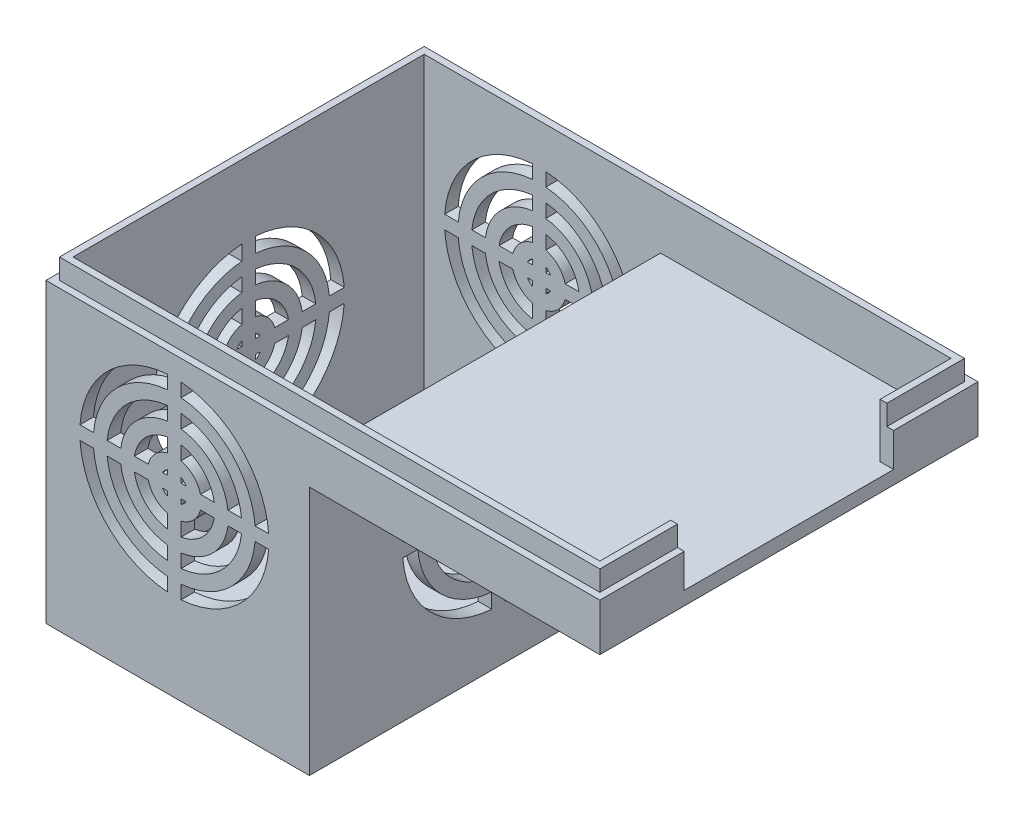
from build123d import *

# Parameters (mm, degrees)
SKETCH1_W               = 82
SKETCH1_H               = 56
BOSS_EXTRUDE1_DEPTH     = 47
SKETCH2_W               = 82
SKETCH2_H               = 56
SKETCH2_W_2             = 80
SKETCH2_H_2             = 54
CUT_EXTRUDE1_DEPTH      = 3
SKETCH3_W               = 43
SKETCH3_H               = 37
CUT_EXTRUDE2_DEPTH      = 72
CUT_EXTRUDE3_DEPTH      = 8
SKETCH4_W               = 35
SKETCH4_H               = 52
CUT_EXTRUDE4_DEPTH      = 37
SKETCH5_W               = 31
SKETCH5_H               = 16
CUT_EXTRUDE5_DEPTH      = 10
CUT_EXTRUDE5_DEPTH_BACK = 11
CUT_EXTRUDE6_DEPTH      = 108
CUT_EXTRUDE7_DEPTH      = 63


with BuildPart() as part:
    # Sketch1 → Boss-Extrude1 (new body)
    with BuildSketch(Plane(origin=(0, 0, 0), x_dir=(1, 0, 0), z_dir=(0, 1, 0))):
        Rectangle(SKETCH1_W, SKETCH1_H)
    extrude(amount=BOSS_EXTRUDE1_DEPTH)

    # Sketch2 → Cut-Extrude1 (cut)
    with BuildSketch(Plane(origin=(0, 47, 0), x_dir=(1, 0, 0), z_dir=(0, 1, 0))):
        Rectangle(SKETCH2_W, SKETCH2_H)
        Rectangle(SKETCH2_W_2, SKETCH2_H_2, mode=Mode.SUBTRACT)
    extrude(amount=-CUT_EXTRUDE1_DEPTH, mode=Mode.SUBTRACT)

    # Sketch3 → Cut-Extrude2 (cut)
    with BuildSketch(Plane.XY.offset(28)):
        with Locations((19.5, 18.5)):
            Rectangle(SKETCH3_W, SKETCH3_H)
    extrude(amount=-CUT_EXTRUDE2_DEPTH, mode=Mode.SUBTRACT)

    # 3DSketch2 → Cut-Extrude3 (cut)
    with BuildSketch(Plane(origin=(39, 47, -26), x_dir=(-0.8320502943378437, 0, 0.5547001962252293), z_dir=(0, -1, 0))):
        Polygon((0, 0), (64.899922958, 43.266615306), (93.744333162, 0), (28.844410204, -43.266615306), align=None)
    extrude(amount=CUT_EXTRUDE3_DEPTH, mode=Mode.SUBTRACT)

    # Sketch4 → Cut-Extrude4 (cut)
    with BuildSketch(Plane(origin=(0, 39, 0), x_dir=(1, 0, 0), z_dir=(0, 1, 0))):
        with Locations((-21.5, 0)):
            Rectangle(SKETCH4_W, SKETCH4_H)
    extrude(amount=-CUT_EXTRUDE4_DEPTH, mode=Mode.SUBTRACT)

    # Sketch5 → Cut-Extrude5 (cut, two sides)
    with BuildSketch(Plane(origin=(40, 0, 0), x_dir=(0, 0, -1), z_dir=(1, 0, 0))) as cut_extrude5_sk:
        with Locations((0, 47)):
            Rectangle(SKETCH5_W, SKETCH5_H)
    extrude(amount=CUT_EXTRUDE5_DEPTH, mode=Mode.SUBTRACT)
    extrude(cut_extrude5_sk.sketch, amount=-CUT_EXTRUDE5_DEPTH_BACK, mode=Mode.SUBTRACT)

    # Sketch6 → Cut-Extrude6 (cut)
    with BuildSketch(Plane(origin=(0, 0, -28), x_dir=(-1, 0, 0), z_dir=(0, 0, -1))):
        with BuildLine():
            ThreePointArc((21, 40.964240044), (12.100505063, 36.899494937), (8.035759956, 28))
            Line((8.035759956, 28), (10.041739257, 28))
            ThreePointArc((10.041739257, 28), (13.514718626, 35.485281374), (21, 38.958260743))
            Line((21, 38.958260743), (21, 40.964240044))
        make_face()
        with BuildLine():
            Line((10.041739257, 26), (8.035759956, 26))
            ThreePointArc((8.035759956, 26), (12.100505063, 17.100505063), (21, 13.035759956))
            Line((21, 13.035759956), (21, 15.041739257))
            ThreePointArc((21, 15.041739257), (13.514718626, 18.514718626), (10.041739257, 26))
        make_face()
        with BuildLine():
            Line((23, 15.041739257), (23, 13.035759956))
            ThreePointArc((23, 13.035759956), (31.899494937, 17.100505063), (35.964240044, 26))
            Line((35.964240044, 26), (33.958260743, 26))
            ThreePointArc((33.958260743, 26), (30.485281374, 18.514718626), (23, 15.041739257))
        make_face()
        with BuildLine():
            ThreePointArc((35.964240044, 28), (31.899494937, 36.899494937), (23, 40.964240044))
            Line((23, 40.964240044), (23, 38.958260743))
            ThreePointArc((23, 38.958260743), (30.485281374, 35.485281374), (33.958260743, 28))
            Line((33.958260743, 28), (35.964240044, 28))
        make_face()
        with BuildLine():
            ThreePointArc((21, 36.949874371), (14.928932188, 34.071067812), (12.050125629, 28))
            Line((12.050125629, 28), (14.062746067, 28))
            ThreePointArc((14.062746067, 28), (16.343145751, 32.656854249), (21, 34.937253933))
            Line((21, 34.937253933), (21, 36.949874371))
        make_face()
        with BuildLine():
            Line((14.062746067, 26), (12.050125629, 26))
            ThreePointArc((12.050125629, 26), (14.928932188, 19.928932188), (21, 17.050125629))
            Line((21, 17.050125629), (21, 19.062746067))
            ThreePointArc((21, 19.062746067), (16.343145751, 21.343145751), (14.062746067, 26))
        make_face()
        with BuildLine():
            Line((23, 19.062746067), (23, 17.050125629))
            ThreePointArc((23, 17.050125629), (29.071067812, 19.928932188), (31.949874371, 26))
            Line((31.949874371, 26), (29.937253933, 26))
            ThreePointArc((29.937253933, 26), (27.656854249, 21.343145751), (23, 19.062746067))
        make_face()
        with BuildLine():
            ThreePointArc((31.949874371, 28), (29.071067812, 34.071067812), (23, 36.949874371))
            Line((23, 36.949874371), (23, 34.937253933))
            ThreePointArc((23, 34.937253933), (27.656854249, 32.656854249), (29.937253933, 28))
            Line((29.937253933, 28), (31.949874371, 28))
        make_face()
        with BuildLine():
            ThreePointArc((27.916079783, 28), (26.242640687, 31.242640687), (23, 32.916079783))
            Line((23, 32.916079783), (23, 30.872983346))
            ThreePointArc((23, 30.872983346), (24.828427125, 29.828427125), (25.872983346, 28))
            Line((25.872983346, 28), (27.916079783, 28))
        make_face()
        with BuildLine():
            Line((18.127016654, 26), (16.083920217, 26))
            ThreePointArc((16.083920217, 26), (17.757359313, 22.757359313), (21, 21.083920217))
            Line((21, 21.083920217), (21, 23.127016654))
            ThreePointArc((21, 23.127016654), (19.171572875, 24.171572875), (18.127016654, 26))
        make_face()
        with BuildLine():
            ThreePointArc((21, 32.916079783), (17.757359313, 31.242640687), (16.083920217, 28))
            Line((16.083920217, 28), (18.127016654, 28))
            ThreePointArc((18.127016654, 28), (19.171572875, 29.828427125), (21, 30.872983346))
            Line((21, 30.872983346), (21, 32.916079783))
        make_face()
        with BuildLine():
            Line((23, 23.127016654), (23, 21.083920217))
            ThreePointArc((23, 21.083920217), (26.242640687, 22.757359313), (27.916079783, 26))
            Line((27.916079783, 26), (25.872983346, 26))
            ThreePointArc((25.872983346, 26), (24.828427125, 24.171572875), (23, 23.127016654))
        make_face()
        with BuildLine():
            ThreePointArc((21, 28.732050808), (20.585786438, 28.414213562), (20.267949192, 28))
            Line((20.267949192, 28), (21, 28))
            Line((21, 28), (21, 28.732050808))
        make_face()
        with BuildLine():
            Line((23, 28.732050808), (23, 28))
            Line((23, 28), (23.732050808, 28))
            ThreePointArc((23.732050808, 28), (23.414213562, 28.414213562), (23, 28.732050808))
        make_face()
        with BuildLine():
            Line((23.732050808, 26), (23, 26))
            Line((23, 26), (23, 25.267949192))
            ThreePointArc((23, 25.267949192), (23.414213562, 25.585786438), (23.732050808, 26))
        make_face()
        with BuildLine():
            Line((21, 26), (20.267949192, 26))
            ThreePointArc((20.267949192, 26), (20.585786438, 25.585786438), (21, 25.267949192))
            Line((21, 25.267949192), (21, 26))
        make_face()
    extrude(amount=-CUT_EXTRUDE6_DEPTH, mode=Mode.SUBTRACT)

    # Sketch7 → Cut-Extrude7 (cut)
    with BuildSketch(Plane.ZY.offset(41)):
        with BuildLine():
            ThreePointArc((-1, 36.164630346), (-10.034987864, 32.046679621), (-14.163456323, 23.016492909))
            Line((-14.163456323, 23.016492909), (-11.956870082, 23.016492909))
            ThreePointArc((-11.956870082, 23.016492909), (-8.47942754, 30.491131172), (-1, 33.958260743))
            Line((-1, 33.958260743), (-1, 36.164630346))
        make_face()
        with BuildLine():
            Line((-11.956870082, 20.983507091), (-14.163456323, 20.983507091))
            ThreePointArc((-14.163456323, 20.983507091), (-10.034987864, 11.953320379), (-1, 7.835369654))
            Line((-1, 7.835369654), (-1, 10.041739257))
            ThreePointArc((-1, 10.041739257), (-8.47942754, 13.508868828), (-11.956870082, 20.983507091))
        make_face()
        with BuildLine():
            Line((1, 10.041739257), (1, 7.835369654))
            ThreePointArc((1, 7.835369654), (10.034987864, 11.953320379), (14.163456323, 20.983507091))
            Line((14.163456323, 20.983507091), (11.956870082, 20.983507091))
            ThreePointArc((11.956870082, 20.983507091), (8.47942754, 13.508868828), (1, 10.041739257))
        make_face()
        with BuildLine():
            ThreePointArc((14.163456323, 23.016492909), (10.034987864, 32.046679621), (1, 36.164630346))
            Line((1, 36.164630346), (1, 33.958260743))
            ThreePointArc((1, 33.958260743), (8.47942754, 30.491131172), (11.956870082, 23.016492909))
            Line((11.956870082, 23.016492909), (14.163456323, 23.016492909))
        make_face()
        with BuildLine():
            ThreePointArc((-1, 31.949874371), (-7.065204392, 29.076926373), (-9.948202962, 23.016492909))
            Line((-9.948202962, 23.016492909), (-7.93515861, 23.016492909))
            ThreePointArc((-7.93515861, 23.016492909), (-5.650973202, 27.662729189), (-1, 29.937253933))
            Line((-1, 29.937253933), (-1, 31.949874371))
        make_face()
        with BuildLine():
            Line((-7.93515861, 20.983507091), (-9.948202962, 20.983507091))
            ThreePointArc((-9.948202962, 20.983507091), (-7.065204392, 14.923073627), (-1, 12.050125629))
            Line((-1, 12.050125629), (-1, 14.062746067))
            ThreePointArc((-1, 14.062746067), (-5.650973202, 16.337270811), (-7.93515861, 20.983507091))
        make_face()
        with BuildLine():
            Line((1, 14.062746067), (1, 12.050125629))
            ThreePointArc((1, 12.050125629), (7.065204392, 14.923073627), (9.948202962, 20.983507091))
            Line((9.948202962, 20.983507091), (7.93515861, 20.983507091))
            ThreePointArc((7.93515861, 20.983507091), (5.650973202, 16.337270811), (1, 14.062746067))
        make_face()
        with BuildLine():
            ThreePointArc((9.948202962, 23.016492909), (7.065204392, 29.076926373), (1, 31.949874371))
            Line((1, 31.949874371), (1, 29.937253933))
            ThreePointArc((1, 29.937253933), (5.650973202, 27.662729189), (7.93515861, 23.016492909))
            Line((7.93515861, 23.016492909), (9.948202962, 23.016492909))
        make_face()
        with BuildLine():
            ThreePointArc((-1, 27.916079783), (-4.236721325, 26.248551802), (-5.913268315, 23.016492909))
            Line((-5.913268315, 23.016492909), (-3.868687396, 23.016492909))
            ThreePointArc((-3.868687396, 23.016492909), (-2.822395019, 24.834446393), (-1, 25.872983346))
            Line((-1, 25.872983346), (-1, 27.916079783))
        make_face()
        with BuildLine():
            Line((-3.868687396, 20.983507091), (-5.913268315, 20.983507091))
            ThreePointArc((-5.913268315, 20.983507091), (-4.236721325, 17.751448198), (-1, 16.083920217))
            Line((-1, 16.083920217), (-1, 18.127016654))
            ThreePointArc((-1, 18.127016654), (-2.822395019, 19.165553607), (-3.868687396, 20.983507091))
        make_face()
        with BuildLine():
            Line((1, 18.127016654), (1, 16.083920217))
            ThreePointArc((1, 16.083920217), (4.236721325, 17.751448198), (5.913268315, 20.983507091))
            Line((5.913268315, 20.983507091), (3.868687396, 20.983507091))
            ThreePointArc((3.868687396, 20.983507091), (2.822395019, 19.165553607), (1, 18.127016654))
        make_face()
        with BuildLine():
            ThreePointArc((5.913268315, 23.016492909), (4.236721325, 26.248551802), (1, 27.916079783))
            Line((1, 27.916079783), (1, 25.872983346))
            ThreePointArc((1, 25.872983346), (2.822395019, 24.834446393), (3.868687396, 23.016492909))
            Line((3.868687396, 23.016492909), (5.913268315, 23.016492909))
        make_face()
        with BuildLine():
            ThreePointArc((-1, 23.732050808), (-1.407445554, 23.420949335), (-1.722423341, 23.016492909))
            Line((-1.722423341, 23.016492909), (-1, 23.016492909))
            Line((-1, 23.016492909), (-1, 23.732050808))
        make_face()
        with BuildLine():
            Line((-1, 20.983507091), (-1.722423341, 20.983507091))
            ThreePointArc((-1.722423341, 20.983507091), (-1.407445554, 20.579050665), (-1, 20.267949192))
            Line((-1, 20.267949192), (-1, 20.983507091))
        make_face()
        with BuildLine():
            Line((1.722423341, 20.983507091), (1, 20.983507091))
            Line((1, 20.983507091), (1, 20.267949192))
            ThreePointArc((1, 20.267949192), (1.407445554, 20.579050665), (1.722423341, 20.983507091))
        make_face()
        with BuildLine():
            Line((1, 23.732050808), (1, 23.016492909))
            Line((1, 23.016492909), (1.722423341, 23.016492909))
            ThreePointArc((1.722423341, 23.016492909), (1.407445554, 23.420949335), (1, 23.732050808))
        make_face()
    extrude(amount=-CUT_EXTRUDE7_DEPTH, mode=Mode.SUBTRACT)


solid = part.part
